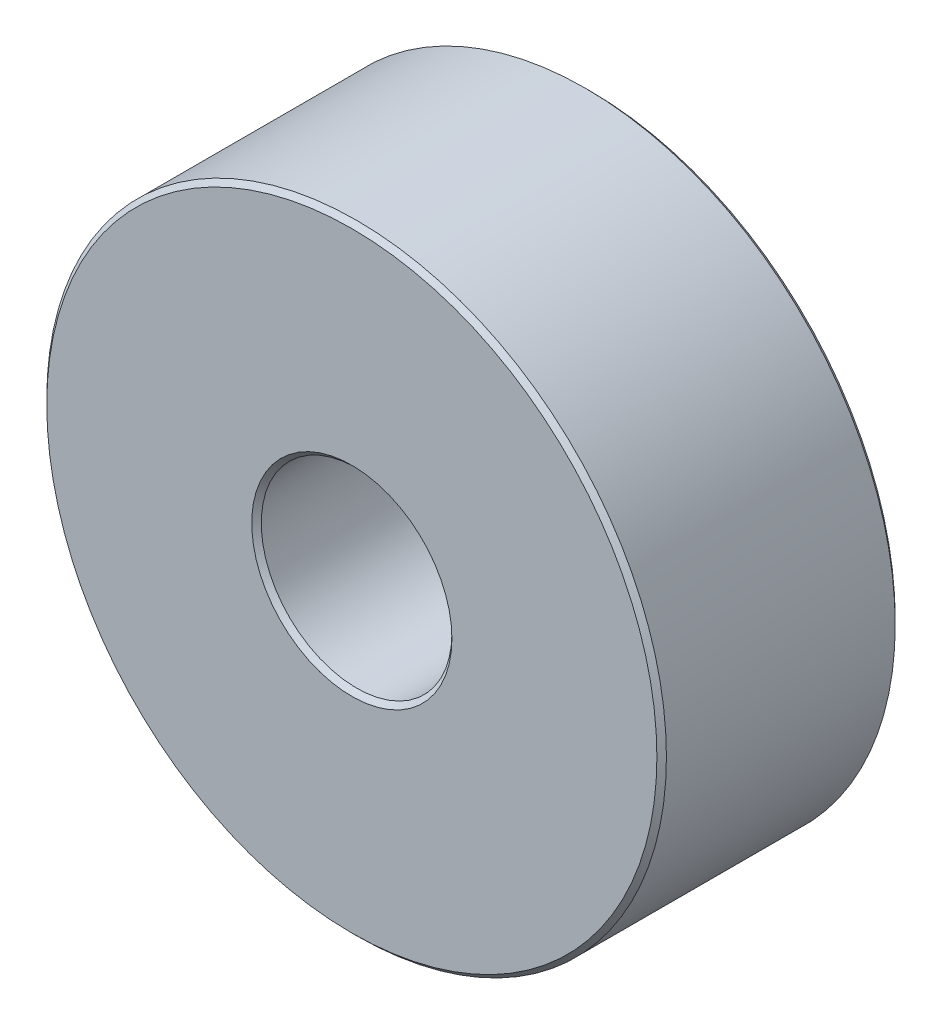
from build123d import *

# Parameters (mm, degrees)
SKETCH_1_R      = 6.5
SKETCH_1_R_2    = 2
EXTRUDE_1_DEPTH = 2.5
CHAMFER_1_SIZE  = 0.1


with BuildPart() as part:
    # 草图1 → 凸台-拉伸1 (new body, symmetric)
    with BuildSketch(Plane.XY):
        Circle(SKETCH_1_R)
        Circle(SKETCH_1_R_2, mode=Mode.SUBTRACT)
    extrude(amount=EXTRUDE_1_DEPTH, both=True)

    # 倒角1
    chamfer_1_edges = [part.edges().sort_by_distance(p)[0] for p in [
        (-6.5, 0, -2.5),
        (-6.5, 0, 2.5),
        (-2, 0, -2.5),
        (-2, 0, 2.5),
    ]]
    chamfer(chamfer_1_edges, length=CHAMFER_1_SIZE)


solid = part.part
